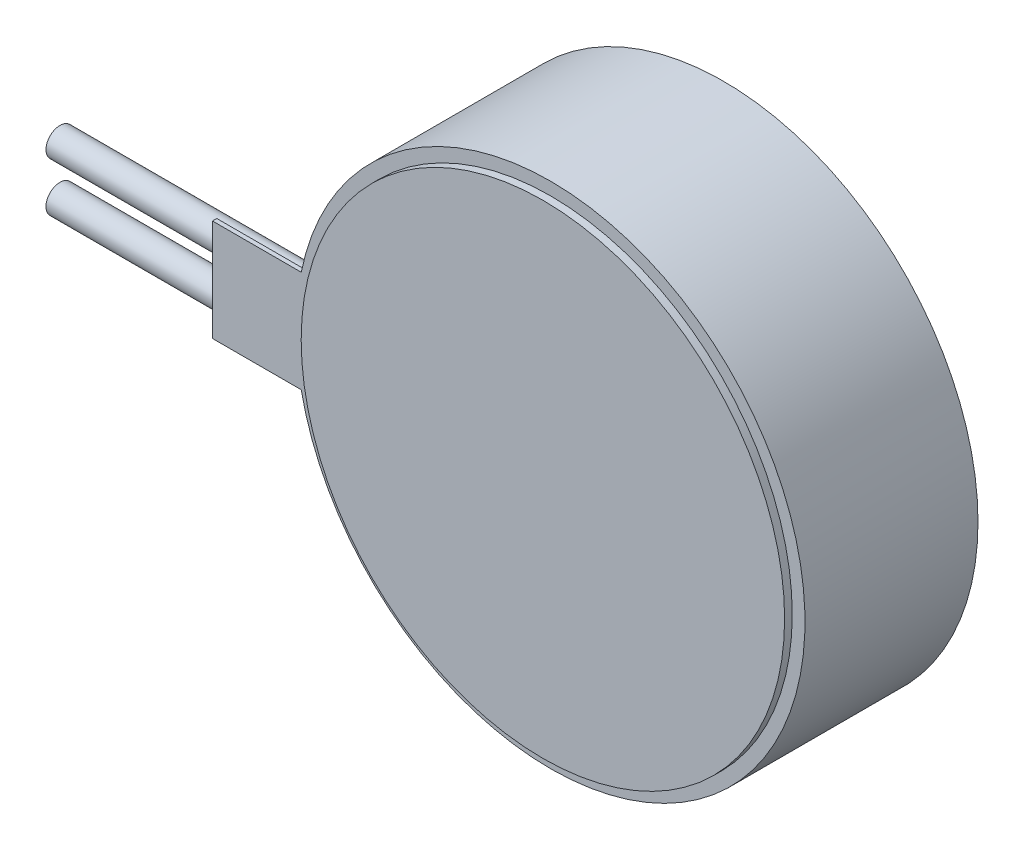
from build123d import *

# Parameters (mm, degrees)
SKETCH1_R             = 5
BOSS_EXTRUDE1_DEPTH   = 3.4
SKETCH2_R             = 4.75
BOSS_EXTRUDE2_DEPTH   = 0.15
BOSS_EXTRUDE3_DEPTH   = 0.085
SKETCH5_R             = 0.275
BOSS_EXTRUDE5_DEPTH   = 10
BOSS_EXTRUDE5_2_DEPTH = 10


with BuildPart() as part:
    # Sketch1 → Boss-Extrude1 (new body)
    with BuildSketch(Plane.XY):
        Circle(SKETCH1_R)
    extrude(amount=BOSS_EXTRUDE1_DEPTH)

    # Sketch2 → Boss-Extrude2 (add)
    with BuildSketch(Plane.XY.offset(3.4)):
        Circle(SKETCH2_R)
    extrude(amount=BOSS_EXTRUDE2_DEPTH)

    # Sketch4 → Boss-Extrude3 (add)
    with BuildSketch(Plane.XY.offset(3.4)):
        with BuildLine():
            Line((-4.643543905, 1), (-6.643543905, 1))
            Line((-6.643543905, 1), (-6.643543905, -1))
            Line((-6.643543905, -1), (-4.643543905, -1))
            ThreePointArc((-4.643543905, -1), (-4.75, 0), (-4.643543905, 1))
        make_face()
    extrude(amount=-BOSS_EXTRUDE3_DEPTH)


with BuildPart() as body_2:
    # Sketch5 → Boss-Extrude5 (new body)
    with BuildSketch(Plane(origin=(0, 0, 0), x_dir=(0, 0, -1), z_dir=(1, 0, 0))):
        with Locations((-3.04, 0.493364025)):
            Circle(SKETCH5_R)
    extrude(amount=-BOSS_EXTRUDE5_DEPTH)


with BuildPart() as body_3:
    # Sketch5 → Boss-Extrude5 2 (new body)
    with BuildSketch(Plane(origin=(0, 0, 0), x_dir=(0, 0, -1), z_dir=(1, 0, 0))):
        with Locations((-3.04, -0.475118647)):
            Circle(SKETCH5_R)
    extrude(amount=-BOSS_EXTRUDE5_2_DEPTH)


solid = Compound([part.part, body_2.part, body_3.part])
